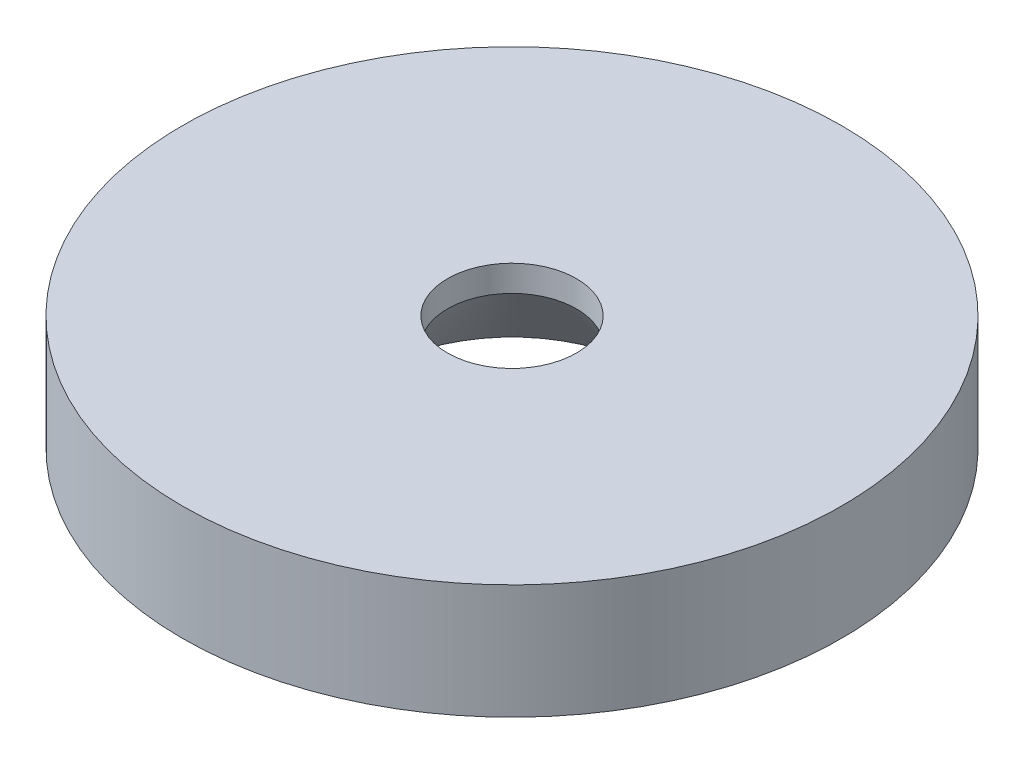
from build123d import *

# Parameters (mm, degrees)
SKETCH1_R           = 11.5
BOSS_EXTRUDE1_DEPTH = 4
SKETCH2_R           = 2.25
CUT_EXTRUDE1_DEPTH  = 5
CHAMFER1_SIZE       = 2.5
CHAMFER1_SIZE2      = 3.087242891


with BuildPart() as part:
    # Sketch1 → Boss-Extrude1 (new body)
    with BuildSketch(Plane(origin=(0, 0, 0), x_dir=(1, 0, 0), z_dir=(0, 1, 0))):
        Circle(SKETCH1_R)
    extrude(amount=BOSS_EXTRUDE1_DEPTH)

    # Sketch2 → Cut-Extrude1 (cut, through all)
    with BuildSketch(Plane(origin=(0, 4, 0), x_dir=(1, 0, 0), z_dir=(0, 1, 0))):
        Circle(SKETCH2_R)
    extrude(amount=-CUT_EXTRUDE1_DEPTH, mode=Mode.SUBTRACT)

    # Chamfer1
    chamfer1_edges = [part.edges().sort_by_distance(p)[0] for p in [
        (-2.25, 0, 0),
    ]]
    chamfer1_side = [part.faces().sort_by_distance(p)[0] for p in [
        (-11.174730881, 0, 0),
    ]]
    chamfer(chamfer1_edges, length=CHAMFER1_SIZE, length2=CHAMFER1_SIZE2, reference=chamfer1_side[0])


solid = part.part
